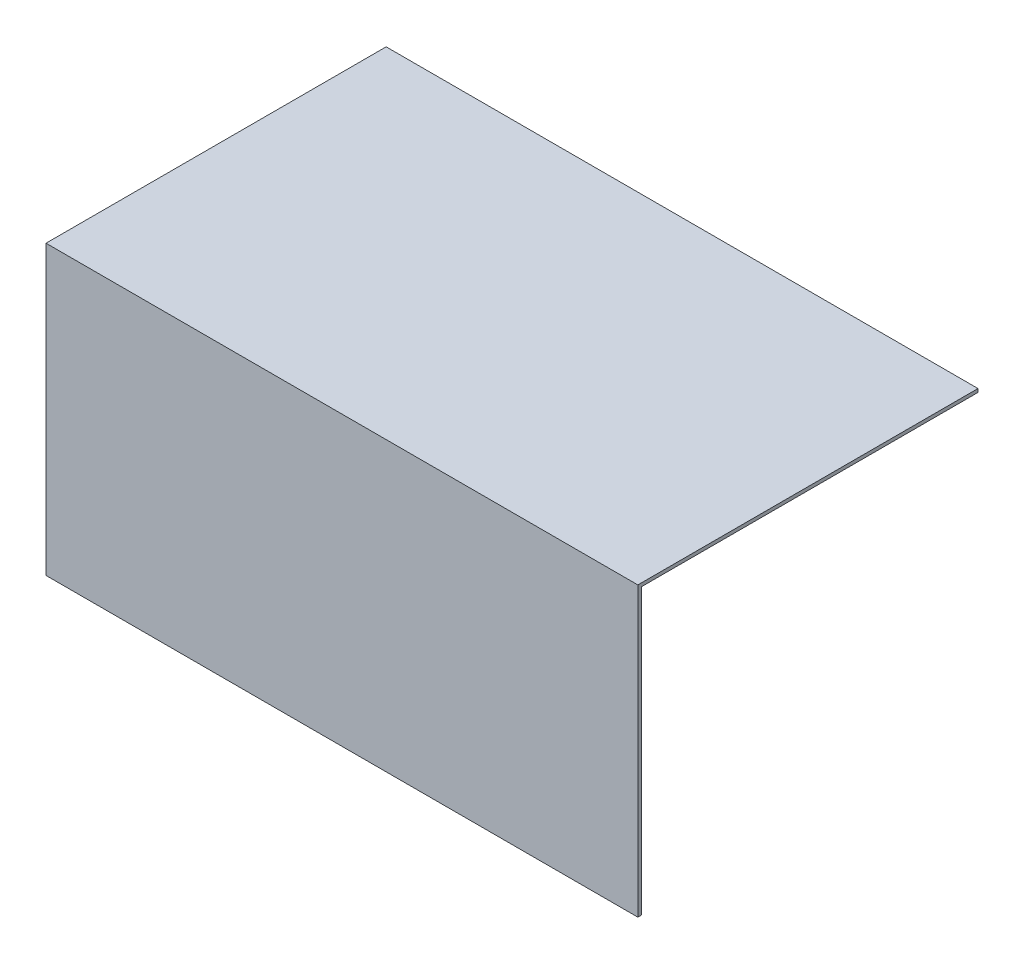
from build123d import *

# Parameters (mm, degrees)
ESQUISSE1_W        = 58
ESQUISSE1_H        = 84.6
BOSS_EXTRU_1_DEPTH = 1
ESQUISSE2_W        = 58
ESQUISSE2_H        = 1
BOSS_EXTRU_2_DEPTH = 99
BOSS_EXTRU_3_DEPTH = 116


with BuildPart() as part:
    # Esquisse1 → Boss.-Extru.1 (new body)
    with BuildSketch(Plane.XY):
        with Locations((-11.490537589, -18.273098988)):
            Rectangle(ESQUISSE1_W, ESQUISSE1_H)
    extrude(amount=BOSS_EXTRU_1_DEPTH)

    # Esquisse2 → Boss.-Extru.2 (add)
    with BuildSketch(Plane(origin=(0, 0, 0), x_dir=(-1, 0, 0), z_dir=(0, 0, -1))):
        with Locations((11.490537589, 23.526901012)):
            Rectangle(ESQUISSE2_W, ESQUISSE2_H)
    extrude(amount=BOSS_EXTRU_2_DEPTH)

    # Esquisse3 → Boss.-Extru.3 (add)
    with BuildSketch(Plane(origin=(17.509462411, 0, 0), x_dir=(0, 0, -1), z_dir=(1, 0, 0))):
        Polygon((99, 24.026901012), (99, 23.026901012), (0, 23.026901012), (0, -60.573098988), (-1, -60.573098988), (-1, 24.026901012), align=None)
    extrude(amount=BOSS_EXTRU_3_DEPTH)


solid = part.part
